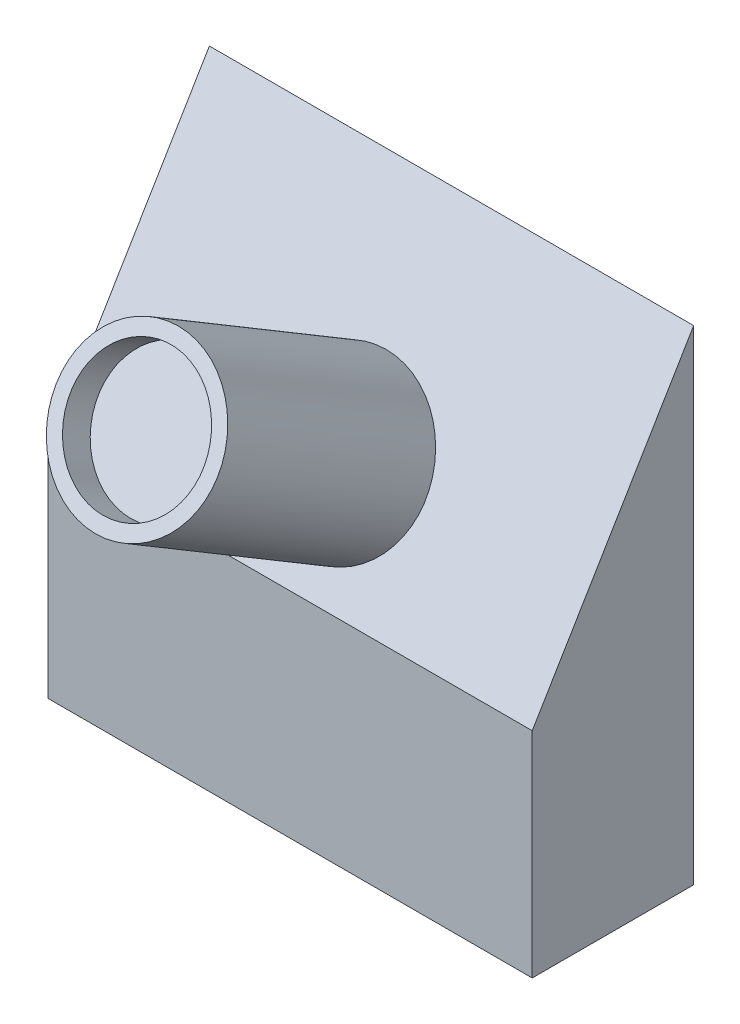
from build123d import *

# Parameters (mm, degrees)
SKETCH2_W           = 30
SKETCH2_H           = 30
BOSS_EXTRUDE2_DEPTH = 10
CUT_EXTRUDE2_DEPTH  = 36
SKETCH6_R           = 5
BOSS_EXTRUDE3_DEPTH = 15
SKETCH7_R           = 4.109940847
CUT_EXTRUDE3_DEPTH  = 2


with BuildPart() as part:
    # Sketch2 → Boss-Extrude2 (new body)
    with BuildSketch(Plane.XY):
        Rectangle(SKETCH2_W, SKETCH2_H)
    extrude(amount=BOSS_EXTRUDE2_DEPTH)

    # Sketch5 → Cut-Extrude2 (cut)
    with BuildSketch(Plane(origin=(15, 0, 0), x_dir=(0, 0, -1), z_dir=(1, 0, 0))):
        Polygon((0, 15), (-10, -1.73373583), (-10, 15), align=None)
    extrude(amount=-CUT_EXTRUDE2_DEPTH, mode=Mode.SUBTRACT)

    # Sketch6 → Boss-Extrude3 (add)
    with BuildSketch(Plane(origin=(0, 3.947182334, 6.605110645), x_dir=(1, 0, 0), z_dir=(0, 0.512977084, 0.858402301))):
        Circle(SKETCH6_R)
    extrude(amount=BOSS_EXTRUDE3_DEPTH)

    # Sketch7 → Cut-Extrude3 (cut)
    with BuildSketch(Plane(origin=(0, 11.641838597, 19.481145166), x_dir=(1, 0, 0), z_dir=(0, 0.512977084, 0.858402301))):
        Circle(SKETCH7_R)
    extrude(amount=-CUT_EXTRUDE3_DEPTH, mode=Mode.SUBTRACT)


solid = part.part
